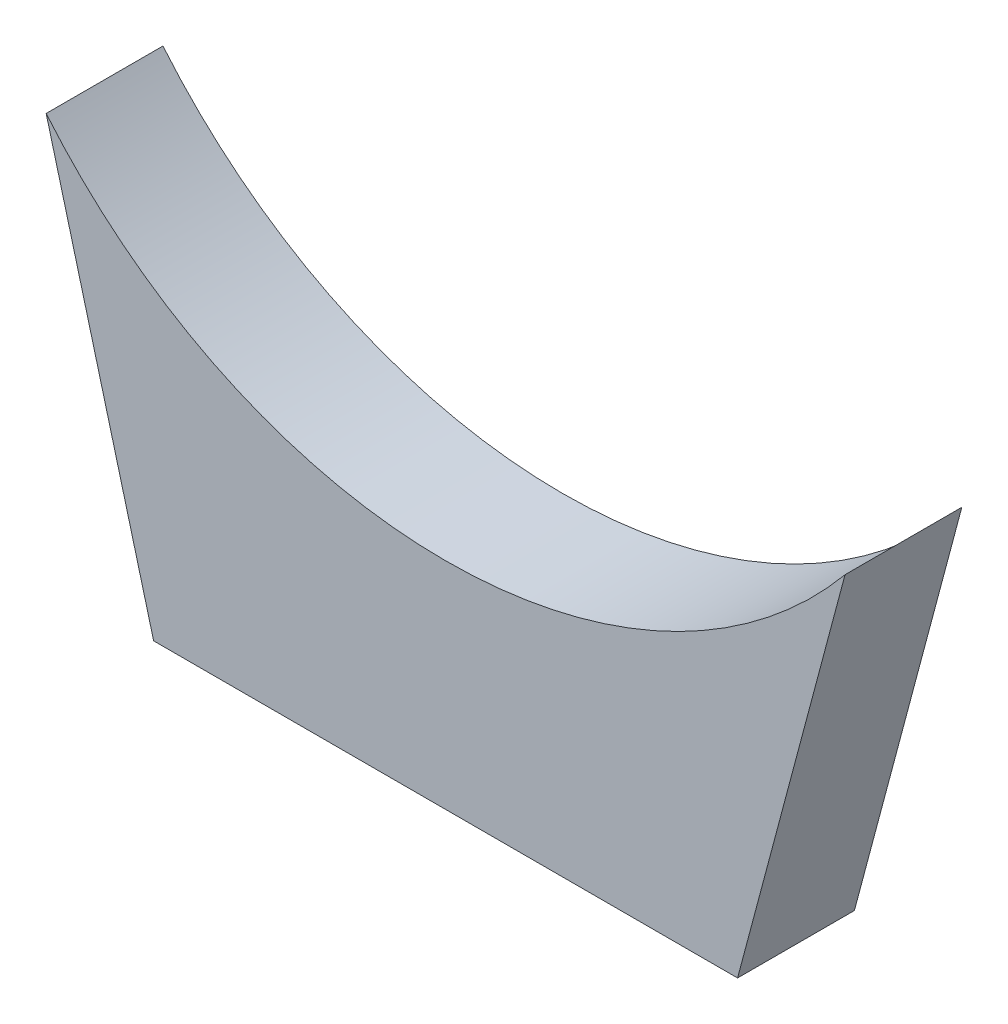
from build123d import *

# Parameters (mm, degrees)
BOSS_EXTRUDE1_DEPTH = 35.56


with BuildPart() as part:
    # 3DSketch2 → Boss-Extrude1 (new body)
    with BuildSketch(Plane(origin=(-27.19462984, 234.775507087, 175.582551715), x_dir=(0.8639455645313932, -0.503585207811481, 0), z_dir=(-2.6823604854784482e-08, -4.601829855119399e-08, 0.9999999999999986))):
        with BuildLine():
            Line((0, 0), (90.066892123, -89.537449949))
            Line((90.066892123, -89.537449949), (243.676413496, 0))
            Line((243.676413496, 0), (210.151573414, 122.495245204))
            ThreePointArc((210.151573414, 122.495245204), (133.855681334, 11.873133589), (0, 0))
        make_face()
    extrude(amount=BOSS_EXTRUDE1_DEPTH)


solid = part.part
